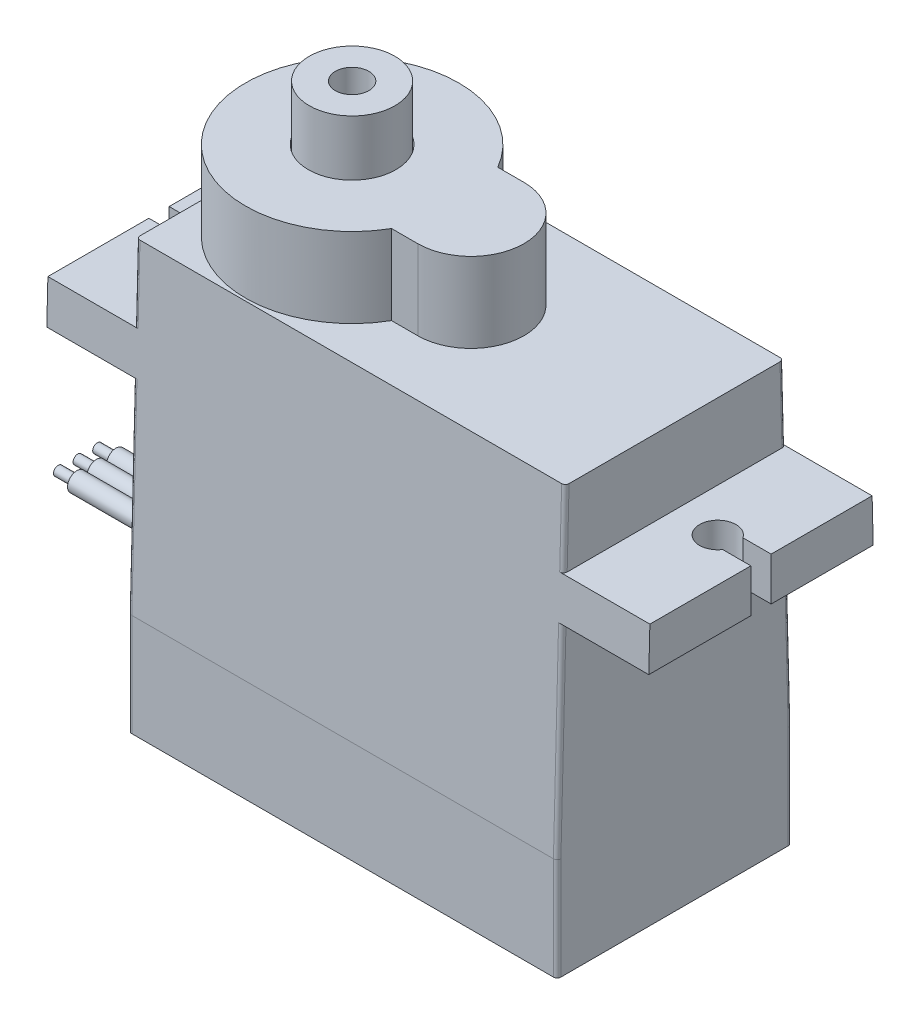
from build123d import *

# Parameters (mm, degrees)
BOSS_EXTRUDE1_DEPTH      = 6.3
BOSS_EXTRUDE2_DEPTH      = 4.28
CUT_EXTRUDE4_DEPTH       = 37.750805433
SKETCH4_R                = 0.975
SKETCH4_W                = 1.511544683
SKETCH4_H                = 1.09
CUT_EXTRUDE1_DEPTH       = 28.01500509
SKETCH5_R                = 1
SKETCH5_R_2              = 0.975
CUT_EXTRUDE2_DEPTH       = 1
SKETCH6_R                = 0.5
BOSS_EXTRUDE4_DEPTH      = 8
SKETCH7_R                = 0.25
BOSS_EXTRUDE5_DEPTH      = 1
FILLET1_R                = 0.3
FILLET3_R                = 0.2
BOSS_EXTRUDE6_DEPTH      = 2.95
BOSS_EXTRUDE6_DEPTH_BACK = 1
SKETCH12_R               = 2.3
SKETCH12_R_2             = 0.9
SKETCH13_R               = 2.35
CUT_EXTRUDE5_DEPTH       = 5


with BuildPart() as part:
    # Sketch1 → Boss-Extrude1 (new, symmetric)
    with BuildSketch(Plane.XY):
        Polygon((-7.1, 6.38), (15.93, 6.38), (15.93, 2.32), (20.57, 2.32), (20.57, 0), (15.93, 0), (15.93, -16.34), (-7.1, -16.34), (-7.1, 0), (-11.74, 0), (-11.74, 2.32), (-7.1, 2.32), align=None)
    extrude(amount=BOSS_EXTRUDE1_DEPTH, both=True)

    # Sketch2 → Boss-Extrude2 (add)
    with BuildSketch(Plane(origin=(0, 6.38, 0), x_dir=(1, 0, 0), z_dir=(0, 1, 0))):
        with BuildLine():
            Line((3.590191336, -2.85), (5, -2.85))
            ThreePointArc((5, -2.85), (7.85, 0), (5, 2.85))
            Line((5, 2.85), (3.590191336, 2.85))
            ThreePointArc((3.590191336, 2.85), (-7.1, 0), (3.590191336, -2.85))
        make_face()
    extrude(amount=BOSS_EXTRUDE2_DEPTH)

    # Sketch11 → Cut-Extrude4 (cut, through all)
    with BuildSketch(Plane.ZY.offset(11.74)):
        Polygon((-5.86, 6.38), (-6.3, -10.84), (-6.3, 6.38), align=None)
    cut_extrude4 = extrude(amount=-CUT_EXTRUDE4_DEPTH, mode=Mode.SUBTRACT)

    # Mirror1: Cut-Extrude4 across plane
    add(cut_extrude4.mirror(Plane.XY), mode=Mode.SUBTRACT)

    # Sketch4 → Cut-Extrude1 (cut, through all)
    with BuildSketch(Plane(origin=(0, 0, 0), x_dir=(1, 0, 0), z_dir=(0, 1, 0))):
        with Locations((-9.42, 0)):
            Circle(SKETCH4_R)
        with Locations((-10.984227659, 0)):
            Rectangle(SKETCH4_W, SKETCH4_H)
    cut_extrude1 = extrude(amount=CUT_EXTRUDE1_DEPTH, mode=Mode.SUBTRACT)

    # Mirror2: Cut-Extrude1 across plane
    add(cut_extrude1.mirror(Plane(origin=(4.415, -10.84, 6.3), x_dir=(0, 0, 1), z_dir=(-1, 0, 0))), mode=Mode.SUBTRACT)

    # Sketch5 → Cut-Extrude2 (cut)
    # profile 1 of 4: a face of its own
    with BuildSketch(Plane.XZ.offset(16.34)):
        with Locations((-5.46, 4.35)):
            Circle(SKETCH5_R)
        with Locations((-5.46, 4.35)):
            Circle(SKETCH5_R_2, mode=Mode.SUBTRACT)
    # profile 2 of 4: a face of its own
    with BuildSketch(Plane.XZ.offset(16.34)):
        with Locations((-5.46, -4.35)):
            Circle(SKETCH5_R)
        with Locations((-5.46, -4.35)):
            Circle(SKETCH5_R_2, mode=Mode.SUBTRACT)
    # profile 3 of 4: a face of its own
    with BuildSketch(Plane.XZ.offset(16.34)):
        with Locations((14.29, -4.35)):
            Circle(SKETCH5_R)
        with Locations((14.29, -4.35)):
            Circle(SKETCH5_R_2, mode=Mode.SUBTRACT)
    # profile 4 of 4: a face of its own
    with BuildSketch(Plane.XZ.offset(16.34)):
        with Locations((14.29, 4.35)):
            Circle(SKETCH5_R)
        with Locations((14.29, 4.35)):
            Circle(SKETCH5_R_2, mode=Mode.SUBTRACT)
    extrude(amount=-CUT_EXTRUDE2_DEPTH, mode=Mode.SUBTRACT)

    # Sketch6 → Boss-Extrude4 (add)
    with BuildSketch(Plane.ZY.offset(7.1)):
        with Locations((0, -11.34)):
            Circle(SKETCH6_R)
        with Locations((1.05, -11.34)):
            Circle(SKETCH6_R)
        with Locations((-1.05, -11.34)):
            Circle(SKETCH6_R)
    extrude(amount=BOSS_EXTRUDE4_DEPTH)

    # Sketch7 → Boss-Extrude5 (add)
    with BuildSketch(Plane.ZY.offset(15.1)):
        with Locations((0, -11.34)):
            Circle(SKETCH7_R)
        with Locations((1.05, -11.34)):
            Circle(SKETCH7_R)
        with Locations((-1.05, -11.34)):
            Circle(SKETCH7_R)
    extrude(amount=BOSS_EXTRUDE5_DEPTH)

    # Fillet1
    fillet1_edges = [part.edges().sort_by_distance(p)[0] for p in [
        (13.315, -16.34, -4.35),
        (13.315, -16.34, 4.35),
        (-6.435, -16.34, -4.35),
        (-6.435, -16.34, 4.35),
    ]]
    fillet(fillet1_edges, radius=FILLET1_R)

    # Fillet3
    fillet3_edges = [part.edges().sort_by_distance(p)[0] for p in [
        (15.93, -13.59, -6.3),
        (15.93, -13.59, 6.3),
        (-7.1, -13.59, -6.3),
        (-7.1, -13.59, 6.3),
        (-7.1, -5.42, 6.161509872),
        (-7.1, -5.42, -6.161509872),
        (15.93, -5.42, 6.161509872),
        (15.93, -5.42, -6.161509872),
        (15.93, 4.35, -5.911869919),
        (15.93, 4.35, 5.911869919),
        (-7.1, 4.35, -5.911869919),
        (-7.1, 4.35, 5.911869919),
    ]]
    fillet(fillet3_edges, radius=FILLET3_R)

    # Sketch13 → Cut-Extrude5 (cut)
    with BuildSketch(Plane(origin=(0, 13.61, 0), x_dir=(1, 0, 0), z_dir=(0, 1, 0))):
        with Locations((-1.375, 0)):
            Circle(SKETCH13_R)
    extrude(amount=-CUT_EXTRUDE5_DEPTH, mode=Mode.SUBTRACT)


with BuildPart() as body_2:
    # Sketch12 → Boss-Extrude6 (new, two sides: drawn at the far end of the back side and taken through both)
    with BuildSketch(Plane(origin=(0, 10.66, 0), x_dir=(1, 0, 0), z_dir=(0, 1, 0)).offset(-BOSS_EXTRUDE6_DEPTH_BACK)):
        with Locations((-1.375, 0)):
            Circle(SKETCH12_R)
        with Locations((-1.375, 0)):
            Circle(SKETCH12_R_2, mode=Mode.SUBTRACT)
    extrude(amount=BOSS_EXTRUDE6_DEPTH + BOSS_EXTRUDE6_DEPTH_BACK)


solid = Compound([part.part, body_2.part])
